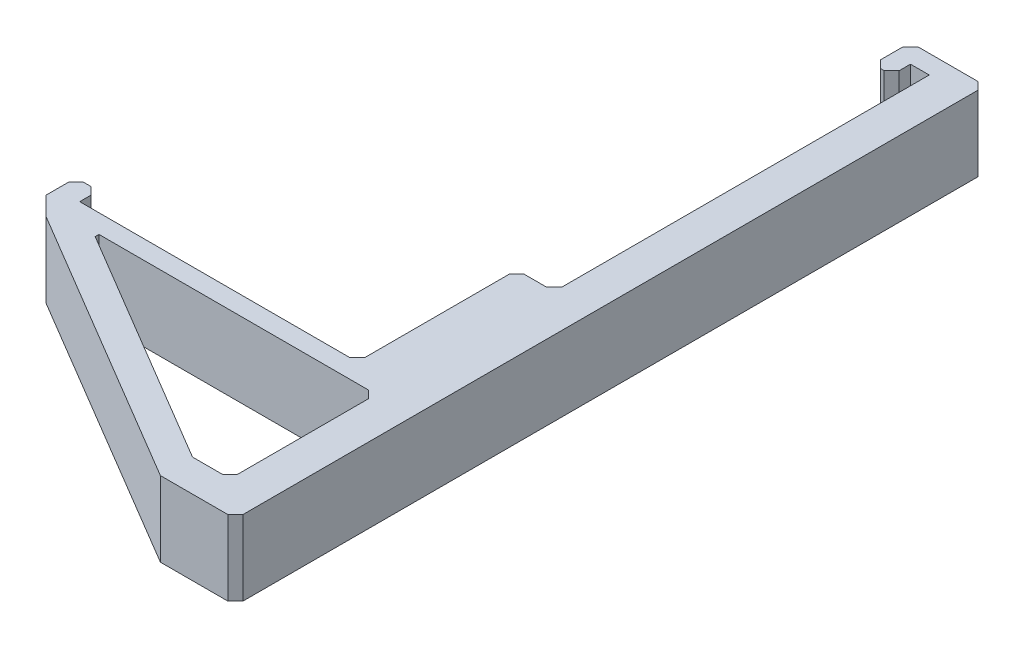
from build123d import *
from OCP.BRepFilletAPI import BRepFilletAPI_MakeChamfer

# Parameters (mm, degrees)
BOSS_EXTRUDE1_DEPTH = 10
CHAMFER1_SIZE       = 1
CHAMFER1_SIZE2      = 0.866089989
CHAMFER2_SIZE       = 1
CHAMFER2_SIZE2      = 2.862737549


with BuildPart() as part:
    # Sketch1 → Boss-Extrude1 (new body)
    with BuildSketch(Plane(origin=(0, 0, 0), x_dir=(1, 0, 0), z_dir=(0, 1, 0))):
        Polygon((0, 0), (0, 45), (0, 47.5), (-2.5, 47.5), (-2.5, 45), (-5, 45), (-5, 50), (5, 50), (5, -50), (-5, -50), (-45, -26.25), (-45, -21.25), (-42.004108019, -21.25), (-42.004108019, -23.75), (-5, -23.75), (-5, -21.25), (-5, -2.5), (0, -2.5), align=None)
        Polygon((-37.793581703, -26.25), (-5, -45.721189136), (0, -45.721189136), (0, -26.25), align=None, mode=Mode.SUBTRACT)
    extrude(amount=BOSS_EXTRUDE1_DEPTH)

    # Chamfer1
    chamfer1_edges = [part.edges().sort_by_distance(p)[0] for p in [
        (-37.793581703, 5, 26.25),
    ]]
    chamfer1_side = [part.faces().sort_by_distance(p)[0] for p in [
        (-21.396790851, 5, 35.985594568),
    ]]
    chamfer(chamfer1_edges, length=CHAMFER1_SIZE, length2=CHAMFER1_SIZE2, reference=chamfer1_side[0])

    # Chamfer2: one chamfer whose edges measure the first distance from different faces: ONE call of the kernel's chamfer builder (chamfer() names one face for all edges)
    chamfer2_edges_1 = [part.edges().sort_by_distance(p)[0] for p in [
        (5, 5, 50),
        (-45, 5, 21.25),
        (-42.004108019, 5, 21.25),
        (-5, 5, 23.75),
        (-5, 5, 2.5),
        (0, 5, 2.5),
        (-2.5, 5, -45),
        (-5, 5, -45),
        (-5, 5, -50),
        (5, 5, -50),
        (0, 5, 45.721189136),
        (0, 5, 26.25),
    ]]
    chamfer2_edges_2 = [part.edges().sort_by_distance(p)[0] for p in [
        (-45, 5, 26.25),
    ]]
    chamfer2_side_2 = [part.faces().sort_by_distance(p)[0] for p in [
        (-45, 5, 23.75),
    ]]
    chamfer2 = BRepFilletAPI_MakeChamfer(part.part.solid().wrapped)
    for e in chamfer2_edges_1:
        chamfer2.Add(CHAMFER2_SIZE, e.wrapped)
    for e in chamfer2_edges_2:
        chamfer2.Add(CHAMFER2_SIZE, CHAMFER2_SIZE2, e.wrapped, chamfer2_side_2[0].wrapped)  # the first distance lies on this face
    add(Compound.cast(chamfer2.Shape()), mode=Mode.REPLACE)


solid = part.part
